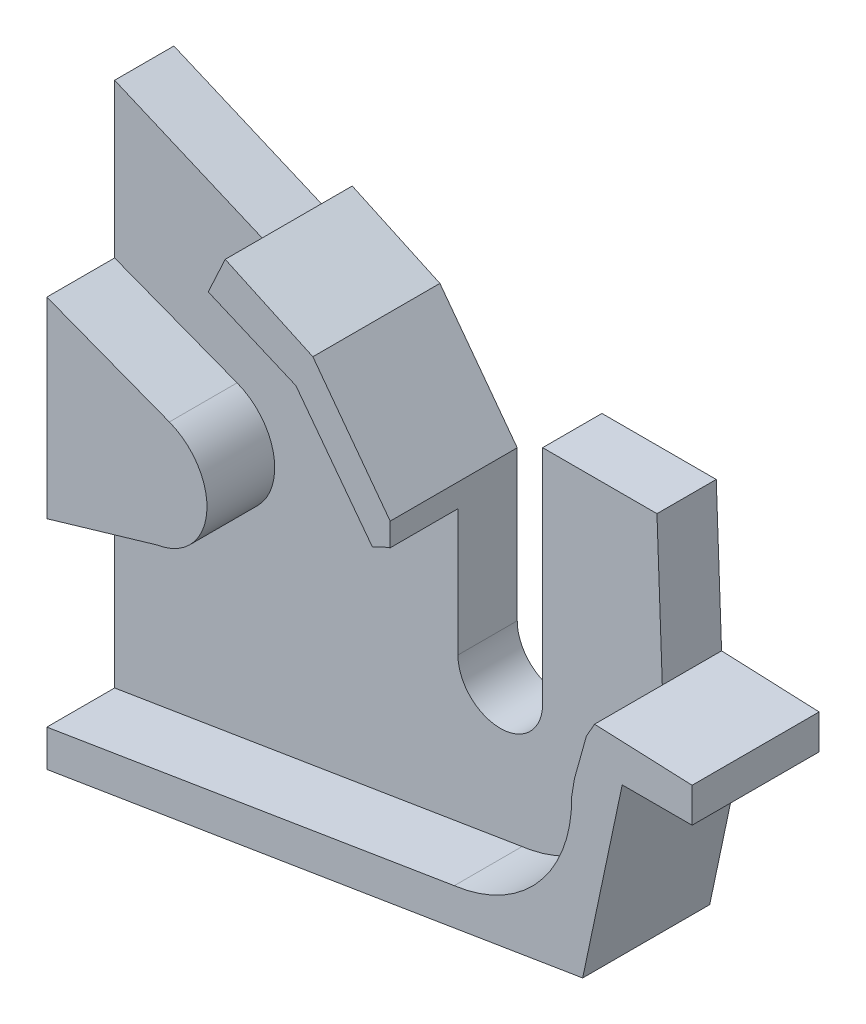
from build123d import *

# Parameters (mm, degrees)
BOSS_EXTRUDE2_DEPTH = 7
BOSS_EXTRUDE3_DEPTH = 15


with BuildPart() as part:
    # Sketch1 → Boss-Extrude2 (new body)
    with BuildSketch(Plane.XY):
        with BuildLine():
            Line((-41.446212302, -25.123400981), (21.822672825, -14.817519442))
            Line((21.822672825, -14.817519442), (26.489801196, 7.266810726))
            Line((26.489801196, 7.266810726), (34.744303123, 7.266810726))
            Line((34.744303123, 7.266810726), (34.744303123, 11.354641566))
            Line((34.744303123, 11.354641566), (23.2245968, 11.838054321))
            Line((23.2245968, 11.838054321), (22.594616957, 29.052034329))
            Line((22.594616957, 29.052034329), (9.094616957, 29.052034329))
            Line((9.094616957, 29.052034329), (9.094616957, 2.846901584))
            ThreePointArc((9.094616957, 2.846901584), (4.094616957, -2.153098416), (-0.905383043, 2.846901584))
            Line((-0.905383043, 2.846901584), (-0.905383043, 20.539136331))
            Line((-0.905383043, 20.539136331), (-10.036820206, 32.783811613))
            Line((-10.036820206, 32.783811613), (-20.38656022, 37.570023616))
            Line((-20.38656022, 37.570023616), (-22.390510994, 33.236665732))
            Line((-22.390510994, 33.236665732), (-41.446212302, 41.354859092))
            Line((-41.446212302, 41.354859092), (-41.446212302, -25.123400981))
        make_face()
        with BuildLine():
            ThreePointArc((7.629856976, -12.798163857), (7.149099204, -12.884055354), (6.665935601, -12.955177206))
            Line((6.665935601, -12.955177206), (7.629856976, -12.798163857))
        make_face(mode=Mode.SUBTRACT)
    extrude(amount=BOSS_EXTRUDE2_DEPTH)

    # Sketch1_7 → Boss-Extrude3 (add)
    with BuildSketch(Plane.XY):
        with BuildLine():
            Line((-41.446212302, -20.792174742), (-41.446212302, -25.123400981))
            Line((-41.446212302, -25.123400981), (21.822672825, -14.817519442))
            Line((21.822672825, -14.817519442), (26.489801196, 7.266810726))
            Line((26.489801196, 7.266810726), (34.744303123, 7.266810726))
            Line((34.744303123, 7.266810726), (34.744303123, 11.354641566))
            Line((34.744303123, 11.354641566), (23.2245968, 11.838054321))
            Line((23.2245968, 11.838054321), (22.257186267, 10.122973627))
            Line((22.257186267, 10.122973627), (20.850125794, 5.080010211))
            Line((20.850125794, 5.080010211), (20.523303512, 3.077207951))
            ThreePointArc((20.523303512, 3.077207951), (16.644968484, -7.575511067), (6.665935601, -12.955177206))
            Line((6.665935601, -12.955177206), (-41.446212302, -20.792174742))
        make_face()
        with BuildLine():
            Line((-41.446212302, 0.515744675), (-28.371326411, 4.352577852))
            ThreePointArc((-28.371326411, 4.352577852), (-22.577436194, 10.464331884), (-26.982644321, 17.641855311))
            Line((-26.982644321, 17.641855311), (-41.446212302, 23.180975488))
            Line((-41.446212302, 23.180975488), (-41.446212302, 0.515744675))
        make_face()
        with BuildLine():
            Line((-12.043630753, 28.828642478), (-3.015328717, 16.855415173))
            ThreePointArc((-3.015328717, 16.855415173), (-1.977696529, 17.370604665), (-0.905383043, 17.809061684))
            Line((-0.905383043, 17.809061684), (-0.905383043, 20.539136331))
            Line((-0.905383043, 20.539136331), (-10.036820206, 32.783811613))
            Line((-10.036820206, 32.783811613), (-20.38656022, 37.570023616))
            Line((-20.38656022, 37.570023616), (-22.390510994, 33.236665732))
            Line((-22.390510994, 33.236665732), (-12.043630753, 28.828642478))
        make_face()
    extrude(amount=BOSS_EXTRUDE3_DEPTH)


solid = part.part
